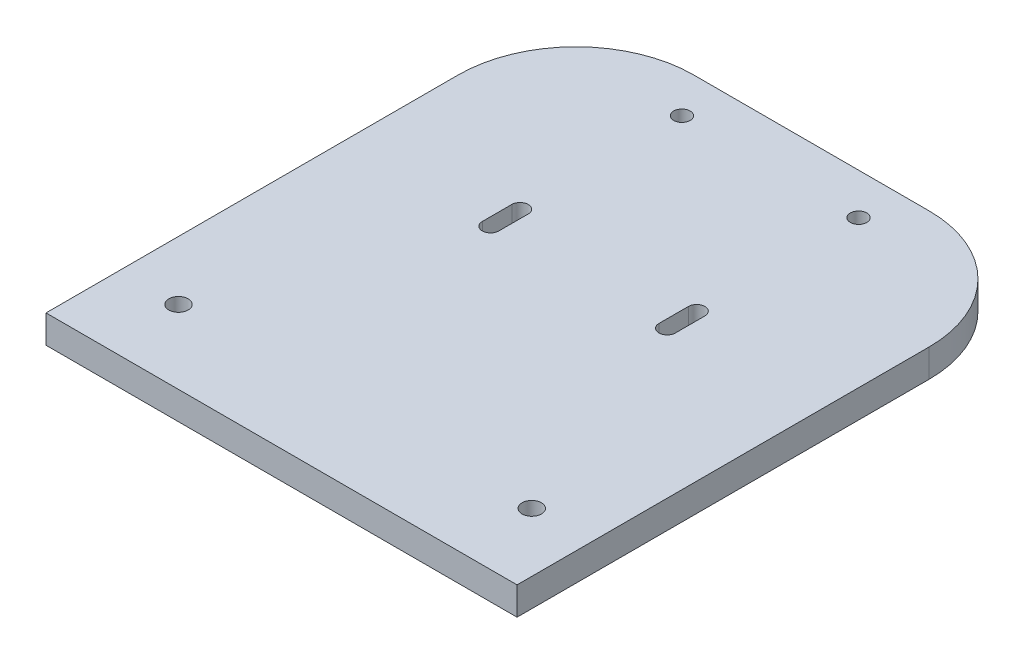
from build123d import *

# Parameters (mm, degrees)
SKETCH1_W           = 80
SKETCH1_H           = 90
BOSS_EXTRUDE1_DEPTH = 4.76
SKETCH2_R           = 1.65
SKETCH2_R_2         = 1.4
CUT_EXTRUDE1_DEPTH  = 5.76
FILLET1_R           = 20


with BuildPart() as part:
    # Sketch1 → Boss-Extrude1 (new body)
    with BuildSketch(Plane(origin=(0, 0, 0), x_dir=(1, 0, 0), z_dir=(0, 1, 0))):
        with Locations((40, 45)):
            Rectangle(SKETCH1_W, SKETCH1_H)
    extrude(amount=BOSS_EXTRUDE1_DEPTH)

    # Sketch2 → Cut-Extrude1 (cut, through all)
    with BuildSketch(Plane(origin=(0, 4.76, 0), x_dir=(1, 0, 0), z_dir=(0, 1, 0))):
        with Locations((10, 12.5)):
            Circle(SKETCH2_R)
        with Locations((70, 12.5)):
            Circle(SKETCH2_R)
        with Locations((25, 83)):
            Circle(SKETCH2_R_2)
        with Locations((55, 83)):
            Circle(SKETCH2_R_2)
        with BuildLine():
            Line((26.4, 55.5), (26.4, 50.5))
            ThreePointArc((26.4, 50.5), (25, 49.1), (23.6, 50.5))
            Line((23.6, 50.5), (23.6, 55.5))
            ThreePointArc((23.6, 55.5), (25, 56.9), (26.4, 55.5))
        make_face()
        with BuildLine():
            Line((53.6, 55.5), (53.6, 50.5))
            ThreePointArc((53.6, 50.5), (55, 49.1), (56.4, 50.5))
            Line((56.4, 50.5), (56.4, 55.5))
            ThreePointArc((56.4, 55.5), (55, 56.9), (53.6, 55.5))
        make_face()
    extrude(amount=-CUT_EXTRUDE1_DEPTH, mode=Mode.SUBTRACT)

    # Fillet1
    fillet1_edges = [part.edges().sort_by_distance(p)[0] for p in [
        (0, 2.38, -90),
        (80, 2.38, -90),
    ]]
    fillet(fillet1_edges, radius=FILLET1_R)


solid = part.part
